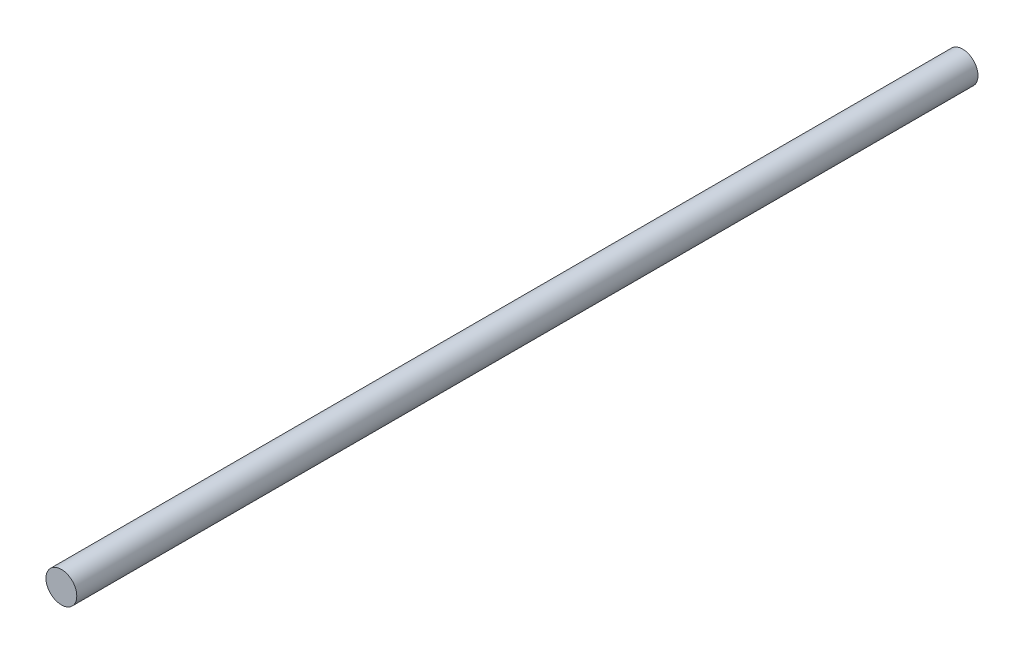
from build123d import *

# Parameters (mm, degrees)
SKETCH1_R           = 5.08
BOSS_EXTRUDE1_DEPTH = 297.18


with BuildPart() as part:
    # Sketch1 → Boss-Extrude1 (new body)
    with BuildSketch(Plane.XY):
        Circle(SKETCH1_R)
    extrude(amount=BOSS_EXTRUDE1_DEPTH)


solid = part.part
